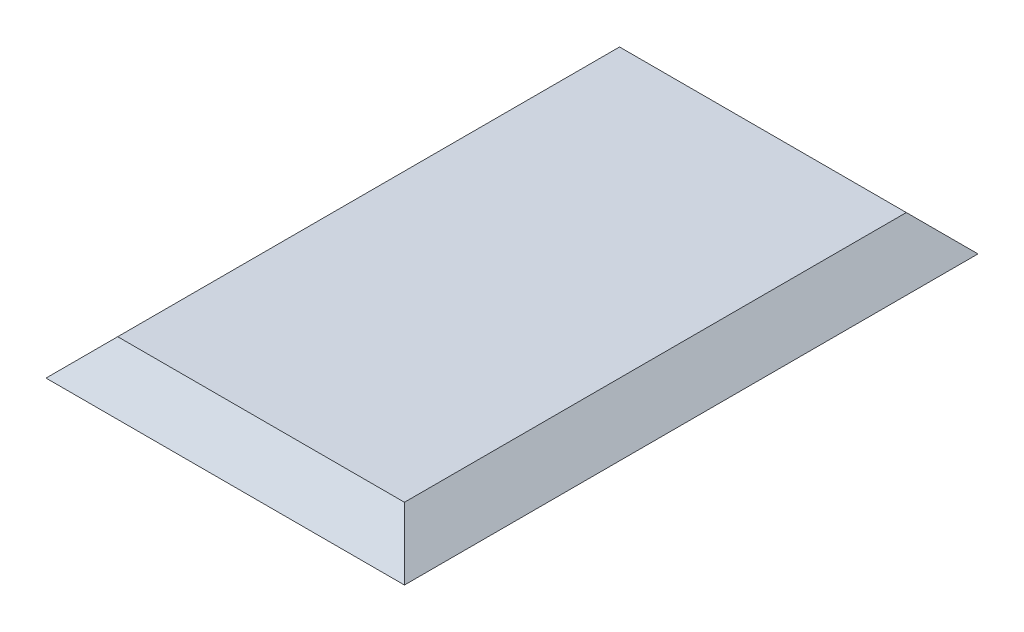
from build123d import *

# Parameters (mm, degrees)
SKETCH1_W               = 50
SKETCH1_H               = 80
BOSS_EXTRUDE1_DEPTH     = 5
CUT_EXTRUDE1_DEPTH      = 41
CUT_EXTRUDE1_DEPTH_BACK = 41
CUT_EXTRUDE2_DEPTH      = 26
CUT_EXTRUDE2_DEPTH_BACK = 26


with BuildPart() as part:
    # Sketch1 → Boss-Extrude1 (new body)
    with BuildSketch(Plane(origin=(0, 0, 0), x_dir=(1, 0, 0), z_dir=(0, 1, 0))):
        Rectangle(SKETCH1_W, SKETCH1_H)
    extrude(amount=BOSS_EXTRUDE1_DEPTH)

    # Sketch2 → Cut-Extrude1 (cut, two sides)
    with BuildSketch(Plane.XY) as cut_extrude1_sk:
        Polygon((-25, 0), (-20, 5), (-25, 5), align=None)
        Polygon((25, 0), (20, 5), (25, 5), align=None)
    extrude(amount=CUT_EXTRUDE1_DEPTH, mode=Mode.SUBTRACT)
    extrude(cut_extrude1_sk.sketch, amount=-CUT_EXTRUDE1_DEPTH_BACK, mode=Mode.SUBTRACT)

    # Sketch3 → Cut-Extrude2 (cut, two sides)
    with BuildSketch(Plane(origin=(0, 0, 0), x_dir=(0, 0, -1), z_dir=(1, 0, 0))) as cut_extrude2_sk:
        Polygon((-40, 0), (-35, 5), (-40, 5), align=None)
        Polygon((40, 0), (35, 5), (40, 5), align=None)
    extrude(amount=CUT_EXTRUDE2_DEPTH, mode=Mode.SUBTRACT)
    extrude(cut_extrude2_sk.sketch, amount=-CUT_EXTRUDE2_DEPTH_BACK, mode=Mode.SUBTRACT)


solid = part.part
